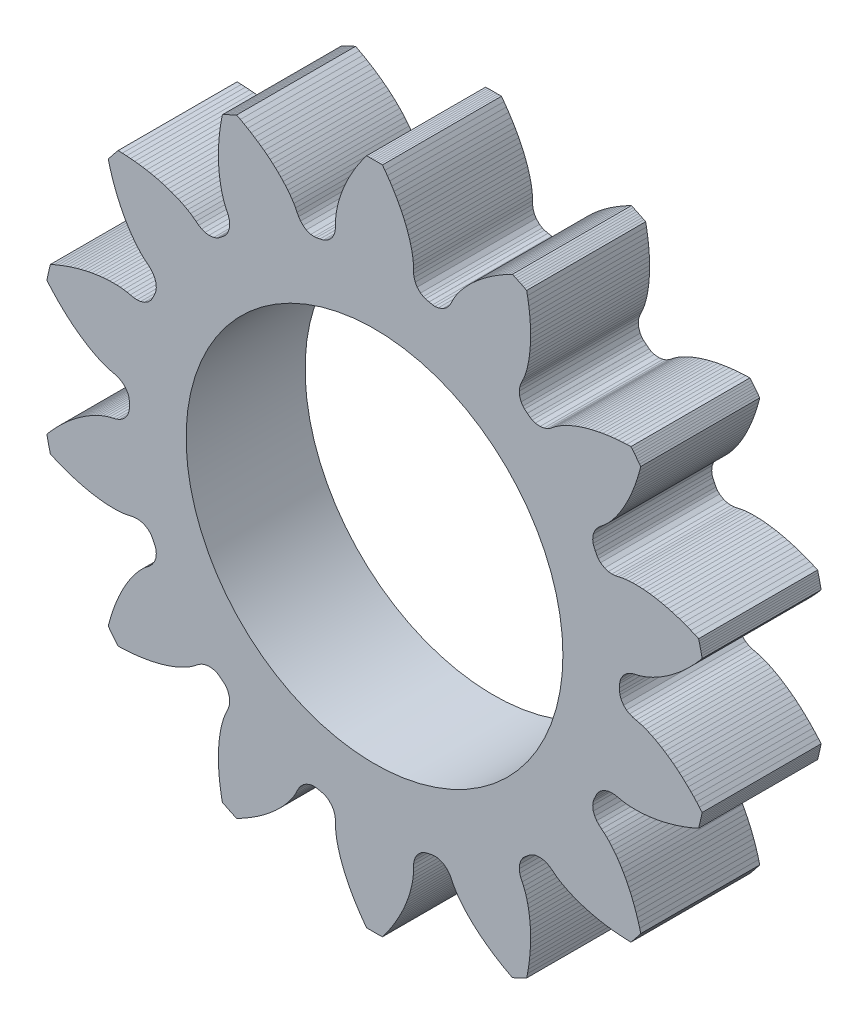
from build123d import *

# Parameters (mm, degrees)
SKETCH3_R      = 4.75
EXTRUDE2_DEPTH = 3


with BuildPart() as part:
    # Sketch3 → Extrude2 (new body)
    with BuildSketch(Plane.XY):
        Polygon((-1.373804192, 6.025054497), (-1.286136761, 6.046506249), (-1.231421429, 6.067958001), (-1.160814916, 6.110861505), (-1.076254106, 6.196668512), (-1.026667784, 6.282475519), (-0.997973478, 6.368282526), (-0.984540616, 6.454089534), (-0.982367604, 6.539896541), (-0.982078667, 6.625703548), (-0.975772464, 6.711510555), (-0.964874551, 6.797317563), (-0.950090272, 6.88312457), (-0.931820743, 6.968931577), (-0.910335182, 7.054738585), (-0.885840729, 7.140545592), (-0.8584406, 7.226352599), (-0.828288559, 7.312159606), (-0.795434627, 7.397966614), (-0.759924885, 7.483773621), (-0.721801696, 7.569580628), (-0.681103905, 7.655387635), (-0.637867032, 7.741194643), (-0.592118153, 7.82700165), (-0.543736138, 7.912808657), (-0.492864536, 7.998615664), (-0.439356223, 8.084422672), (-0.383311488, 8.170229679), (-0.324544258, 8.256036686), (-0.263173217, 8.341843694), (-0.199012902, 8.427650701), (-0.149265744, 8.428678556), (-0.099513385, 8.429412765), (-0.049757559, 8.4298533), (0, 8.430000147), (0.049757559, 8.4298533), (0.099513385, 8.429412765), (0.149265744, 8.428678556), (0.199012902, 8.427650701), (0.263173217, 8.341843694), (0.324544258, 8.256036686), (0.383311488, 8.170229679), (0.439356223, 8.084422672), (0.492864536, 7.998615664), (0.543736138, 7.912808657), (0.592118153, 7.82700165), (0.637867032, 7.741194643), (0.681103905, 7.655387635), (0.721801696, 7.569580628), (0.759924885, 7.483773621), (0.795434627, 7.397966614), (0.828288559, 7.312159606), (0.8584406, 7.226352599), (0.885840729, 7.140545592), (0.910335182, 7.054738585), (0.931820743, 6.968931577), (0.950090272, 6.88312457), (0.964874551, 6.797317563), (0.975772464, 6.711510555), (0.982078667, 6.625703548), (0.982367604, 6.539896541), (0.984540616, 6.454089534), (0.997973478, 6.368282526), (1.026667784, 6.282475519), (1.076254106, 6.196668512), (1.160814916, 6.110861505), (1.231421429, 6.067958001), (1.286136761, 6.046506249), (1.373804192, 6.025054497), (1.376418366, 6.024457829), (1.464711558, 6.005747717), (1.523315935, 6.001334985), (1.605545338, 6.009354688), (1.718962261, 6.04997457), (1.800868258, 6.105769313), (1.8639512, 6.170628762), (1.913284056, 6.242109904), (1.952472137, 6.318476512), (1.989962725, 6.395660589), (2.032874683, 6.470233872), (2.079923628, 6.542814887), (2.130474069, 6.613709671), (2.18416461, 6.683092262), (2.240752697, 6.751079468), (2.300051702, 6.817761166), (2.36196863, 6.883182138), (2.426364946, 6.9474091), (2.493195581, 7.010463755), (2.562419018, 7.072366098), (2.63399709, 7.133134508), (2.707894798, 7.19278584), (2.784080139, 7.251335506), (2.86252872, 7.308795254), (2.943349675, 7.365112526), (3.026413669, 7.420349608), (3.111853259, 7.474442663), (3.199578085, 7.527435206), (3.289755795, 7.579246503), (3.382279458, 7.629928048), (3.477316169, 7.679399373), (3.52258278, 7.658740956), (3.567726667, 7.637815715), (3.612746258, 7.61662438), (3.657639984, 7.595167688), (3.702406282, 7.573446388), (3.747043591, 7.551461236), (3.791550356, 7.529212998), (3.835925027, 7.506702449), (3.856501208, 7.40155489), (3.87456434, 7.29761755), (3.89028152, 7.194809963), (3.903545816, 7.093183622), (3.914524876, 6.992657792), (3.923128339, 6.893275989), (3.929488764, 6.794974377), (3.933476814, 6.697815241), (3.935201626, 6.601746022), (3.934638803, 6.50677847), (3.931756345, 6.412927996), (3.926519252, 6.320211454), (3.918889356, 6.228647225), (3.908825142, 6.138255303), (3.896281539, 6.04905739), (3.881120014, 5.961120203), (3.863247571, 5.874488525), (3.842477582, 5.789252232), (3.818567492, 5.705528131), (3.791155907, 5.623490262), (3.759607334, 5.543444661), (3.722637392, 5.466009854), (3.687364943, 5.387757577), (3.662237269, 5.304619834), (3.650859681, 5.214860399), (3.658305147, 5.116036258), (3.69726154, 5.002037255), (3.742260677, 4.932747516), (3.782249922, 4.889680063), (3.851927982, 4.83231523), (3.854024386, 4.830643403), (3.92545579, 4.775477194), (3.976341896, 4.746073973), (4.053907647, 4.717621476), (4.17371707, 4.705008966), (4.271720255, 4.719740613), (4.356697482, 4.750806294), (4.432159355, 4.793803854), (4.500600825, 4.845604718), (4.567867594, 4.898878612), (4.638886067, 4.947448018), (4.712767424, 4.992427481), (4.789071891, 5.03436846), (4.867549376, 5.073584562), (4.948032024, 5.110286267), (5.030390685, 5.144635527), (5.114561006, 5.176713037), (5.200447115, 5.206639016), (5.288017827, 5.234452572), (5.377244408, 5.260189732), (5.468100448, 5.283883616), (5.560561725, 5.305564596), (5.654606094, 5.325260441), (5.750216673, 5.342992321), (5.847468986, 5.358665532), (5.946273531, 5.372392307), (6.046722038, 5.384057617), (6.148751978, 5.393739873), (6.252479367, 5.401293596), (6.357830205, 5.406811578), (6.464920126, 5.410148818), (6.496740582, 5.371895781), (6.528334697, 5.333455592), (6.559701372, 5.29482959), (6.590839512, 5.256019121), (6.621748033, 5.217025537), (6.652425859, 5.177850197), (6.68287192, 5.138494465), (6.713085156, 5.098959713), (6.686001838, 4.995297366), (6.657179437, 4.893815759), (6.626733586, 4.794369895), (6.594590287, 4.697052563), (6.560865555, 4.601718285), (6.52549686, 4.508445471), (6.488575933, 4.417119094), (6.450013273, 4.327851387), (6.409884403, 4.240547644), (6.36817244, 4.155229036), (6.324855241, 4.071923332), (6.279908583, 3.990660904), (6.233306055, 3.911474872), (6.185018925, 3.834401263), (6.135016006, 3.759479186), (6.083201428, 3.686828857), (6.029510837, 3.616530975), (5.973815082, 3.548747489), (5.915946309, 3.48368888), (5.855654427, 3.421668754), (5.792499661, 3.363238572), (5.72559319, 3.309512878), (5.659861421, 3.254314155), (5.601150054, 3.190312127), (5.551954042, 3.114378221), (5.515783988, 3.022110279), (5.501420172, 2.902498182), (5.511899302, 2.82054589), (5.529242099, 2.764392773), (5.567130193, 2.682476666), (5.56829361, 2.680060807), (5.60871536, 2.599364845), (5.641804578, 2.550794805), (5.699343829, 2.491505472), (5.801816026, 2.428158633), (5.896505667, 2.3989094), (5.986546397, 2.390028375), (6.073191137, 2.396026158), (6.157330324, 2.413001483), (6.241050265, 2.431813646), (6.326109173, 2.444759408), (6.412189834, 2.453228584), (6.499135292, 2.457908833), (6.586856291, 2.459191215), (6.675292924, 2.457338197), (6.764399099, 2.452551726), (6.854151848, 2.444932432), (6.944516955, 2.43463022), (7.035483289, 2.421693861), (7.127040596, 2.406168277), (7.21917945, 2.388094771), (7.311891207, 2.367511214), (7.405167963, 2.344452235), (7.499003693, 2.318944232), (7.593425351, 2.29086911), (7.688400993, 2.260366821), (7.78396336, 2.227293928), (7.880090133, 2.191748208), (7.976822718, 2.15354825), (8.074134706, 2.112809764), (8.172067366, 2.069351938), (8.184139235, 2.021080764), (8.195925976, 1.972739178), (8.207427179, 1.924328863), (8.218642443, 1.875851506), (8.229571376, 1.827308796), (8.240213599, 1.778702425), (8.25056874, 1.730034085), (8.260636439, 1.681305472), (8.191257806, 1.599659935), (8.121258501, 1.520733738), (8.050679793, 1.44434607), (7.979495274, 1.370612639), (7.907746347, 1.299352035), (7.835410697, 1.230662035), (7.762521062, 1.164399202), (7.689045498, 1.100703488), (7.615010961, 1.039456799), (7.540411425, 0.980685531), (7.465238987, 0.924424314), (7.389485001, 0.87071102), (7.313140042, 0.819586949), (7.236193856, 0.771097027), (7.158635312, 0.725290022), (7.080430194, 0.68231584), (7.001555535, 0.642275111), (6.921965241, 0.605369783), (6.841599406, 0.571862321), (6.760368773, 0.542143786), (6.678116389, 0.516901837), (6.594525037, 0.497526289), (6.511352931, 0.476313904), (6.430686378, 0.444123976), (6.353415815, 0.39705524), (6.280794164, 0.329618296), (6.215955068, 0.228083746), (6.189838672, 0.149700558), (6.181100067, 0.091583591), (6.179693994, 0.001340701), (6.179693994, -0.001340701), (6.181100067, -0.091583591), (6.189838672, -0.149700558), (6.215955068, -0.228083746), (6.280794164, -0.329618296), (6.353415815, -0.39705524), (6.430686378, -0.444123976), (6.511352931, -0.476313904), (6.594525037, -0.497526289), (6.678116389, -0.516901837), (6.760368773, -0.542143786), (6.841599406, -0.571862321), (6.921965241, -0.605369783), (7.001555535, -0.642275111), (7.080430194, -0.68231584), (7.158635312, -0.725290022), (7.236193856, -0.771097027), (7.313140042, -0.819586949), (7.389485001, -0.87071102), (7.465238987, -0.924424314), (7.540411425, -0.980685531), (7.615010961, -1.039456799), (7.689045498, -1.100703488), (7.762521062, -1.164399202), (7.835410697, -1.230662035), (7.907746347, -1.299352035), (7.979495274, -1.370612639), (8.050679793, -1.44434607), (8.121258501, -1.520733738), (8.191257806, -1.599659935), (8.260636439, -1.681305472), (8.25056874, -1.730034085), (8.240213599, -1.778702425), (8.229571376, -1.827308796), (8.218642443, -1.875851506), (8.207427179, -1.924328863), (8.195925976, -1.972739178), (8.184139235, -2.021080764), (8.172067366, -2.069351938), (8.074134706, -2.112809764), (7.976822718, -2.15354825), (7.880090133, -2.191748208), (7.78396336, -2.227293928), (7.688400993, -2.260366821), (7.593425351, -2.29086911), (7.499003693, -2.318944232), (7.405167963, -2.344452235), (7.311891207, -2.367511214), (7.21917945, -2.388094771), (7.127040596, -2.406168277), (7.035483289, -2.421693861), (6.944516955, -2.43463022), (6.854151848, -2.444932432), (6.764399099, -2.452551726), (6.675292924, -2.457338197), (6.586856291, -2.459191215), (6.499135292, -2.457908833), (6.412189834, -2.453228584), (6.326109173, -2.444759408), (6.241050265, -2.431813646), (6.157330324, -2.413001483), (6.073191137, -2.396026158), (5.986546397, -2.390028375), (5.896505667, -2.3989094), (5.801816026, -2.428158633), (5.699343829, -2.491505472), (5.641804578, -2.550794805), (5.60871536, -2.599364845), (5.56829361, -2.680060807), (5.567130193, -2.682476666), (5.529242099, -2.764392773), (5.511899302, -2.82054589), (5.501420172, -2.902498182), (5.515783988, -3.022110279), (5.551954042, -3.114378221), (5.601150054, -3.190312127), (5.659861421, -3.254314155), (5.72559319, -3.309512878), (5.792499661, -3.363238572), (5.855654427, -3.421668754), (5.915946309, -3.48368888), (5.973815082, -3.548747489), (6.029510837, -3.616530975), (6.083201428, -3.686828857), (6.135016006, -3.759479186), (6.185018925, -3.834401263), (6.233306055, -3.911474872), (6.279908583, -3.990660904), (6.324855241, -4.071923332), (6.36817244, -4.155229036), (6.409884403, -4.240547644), (6.450013273, -4.327851387), (6.488575933, -4.417119094), (6.52549686, -4.508445471), (6.560865555, -4.601718285), (6.594590287, -4.697052563), (6.626733586, -4.794369895), (6.657179437, -4.893815759), (6.686001838, -4.995297366), (6.713085156, -5.098959713), (6.68287192, -5.138494465), (6.652425859, -5.177850197), (6.621748033, -5.217025537), (6.590839512, -5.256019121), (6.559701372, -5.29482959), (6.528334697, -5.333455592), (6.496740582, -5.371895781), (6.464920126, -5.410148818), (6.357830205, -5.406811578), (6.252479367, -5.401293596), (6.148751978, -5.393739873), (6.046722038, -5.384057617), (5.946273531, -5.372392307), (5.847468986, -5.358665532), (5.750216673, -5.342992321), (5.654606094, -5.325260441), (5.560561725, -5.305564596), (5.468100448, -5.283883616), (5.377244408, -5.260189732), (5.288017827, -5.234452572), (5.200447115, -5.206639016), (5.114561006, -5.176713037), (5.030390685, -5.144635527), (4.948032024, -5.110286267), (4.867549376, -5.073584562), (4.789071891, -5.03436846), (4.712767424, -4.992427481), (4.638886067, -4.947448018), (4.567867594, -4.898878612), (4.500600825, -4.845604718), (4.432159355, -4.793803854), (4.356697482, -4.750806294), (4.271720255, -4.719740613), (4.17371707, -4.705008966), (4.053907647, -4.717621476), (3.976341896, -4.746073973), (3.92545579, -4.775477194), (3.854024386, -4.830643403), (3.851927982, -4.83231523), (3.782249922, -4.889680063), (3.742260677, -4.932747516), (3.69726154, -5.002037255), (3.658305147, -5.116036258), (3.650859681, -5.214860399), (3.662237269, -5.304619834), (3.687364943, -5.387757577), (3.722637392, -5.466009854), (3.759607334, -5.543444661), (3.791155907, -5.623490262), (3.818567492, -5.705528131), (3.842477582, -5.789252232), (3.863247571, -5.874488525), (3.881120014, -5.961120203), (3.896281539, -6.04905739), (3.908825142, -6.138255303), (3.918889356, -6.228647225), (3.926519252, -6.320211454), (3.931756345, -6.412927996), (3.934638803, -6.50677847), (3.935201626, -6.601746022), (3.933476814, -6.697815241), (3.929488764, -6.794974377), (3.923128339, -6.893275989), (3.914524876, -6.992657792), (3.903545816, -7.093183622), (3.89028152, -7.194809963), (3.87456434, -7.29761755), (3.856501208, -7.40155489), (3.835925027, -7.506702449), (3.791550356, -7.529212998), (3.747043591, -7.551461236), (3.702406282, -7.573446388), (3.657639984, -7.595167688), (3.612746258, -7.61662438), (3.567726667, -7.637815715), (3.52258278, -7.658740956), (3.477316169, -7.679399373), (3.382279458, -7.629928048), (3.289755795, -7.579246503), (3.199578085, -7.527435206), (3.111853259, -7.474442663), (3.026413669, -7.420349608), (2.943349675, -7.365112526), (2.86252872, -7.308795254), (2.784080139, -7.251335506), (2.707894798, -7.19278584), (2.63399709, -7.133134508), (2.562419018, -7.072366098), (2.493195581, -7.010463755), (2.426364946, -6.9474091), (2.36196863, -6.883182138), (2.300051702, -6.817761166), (2.240752697, -6.751079468), (2.18416461, -6.683092262), (2.130474069, -6.613709671), (2.079923628, -6.542814887), (2.032874683, -6.470233872), (1.989962725, -6.395660589), (1.952472137, -6.318476512), (1.913284056, -6.242109904), (1.8639512, -6.170628762), (1.800868258, -6.105769313), (1.718962261, -6.04997457), (1.605545338, -6.009354688), (1.523315935, -6.001334985), (1.464711558, -6.005747717), (1.376418366, -6.024457829), (1.373804192, -6.025054497), (1.286136761, -6.046506249), (1.231421429, -6.067958001), (1.160814916, -6.110861505), (1.076254106, -6.196668512), (1.026667784, -6.282475519), (0.997973478, -6.368282526), (0.984540616, -6.454089534), (0.982367604, -6.539896541), (0.982078667, -6.625703548), (0.975772464, -6.711510555), (0.964874551, -6.797317563), (0.950090272, -6.88312457), (0.931820743, -6.968931577), (0.910335182, -7.054738585), (0.885840729, -7.140545592), (0.8584406, -7.226352599), (0.828288559, -7.312159606), (0.795434627, -7.397966614), (0.759924885, -7.483773621), (0.721801696, -7.569580628), (0.681103905, -7.655387635), (0.637867032, -7.741194643), (0.592118153, -7.82700165), (0.543736138, -7.912808657), (0.492864536, -7.998615664), (0.439356223, -8.084422672), (0.383311488, -8.170229679), (0.324544258, -8.256036686), (0.263173217, -8.341843694), (0.199012902, -8.427650701), (0.149265744, -8.428678556), (0.099513385, -8.429412765), (0.049757559, -8.4298533), (0, -8.430000147), (-0.049757559, -8.4298533), (-0.099513385, -8.429412765), (-0.149265744, -8.428678556), (-0.199012902, -8.427650701), (-0.263173217, -8.341843694), (-0.324544258, -8.256036686), (-0.383311488, -8.170229679), (-0.439356223, -8.084422672), (-0.492864536, -7.998615664), (-0.543736138, -7.912808657), (-0.592118153, -7.82700165), (-0.637867032, -7.741194643), (-0.681103905, -7.655387635), (-0.721801696, -7.569580628), (-0.759924885, -7.483773621), (-0.795434627, -7.397966614), (-0.828288559, -7.312159606), (-0.8584406, -7.226352599), (-0.885840729, -7.140545592), (-0.910335182, -7.054738585), (-0.931820743, -6.968931577), (-0.950090272, -6.88312457), (-0.964874551, -6.797317563), (-0.975772464, -6.711510555), (-0.982078667, -6.625703548), (-0.982367604, -6.539896541), (-0.984540616, -6.454089534), (-0.997973478, -6.368282526), (-1.026667784, -6.282475519), (-1.076254106, -6.196668512), (-1.160814916, -6.110861505), (-1.231421429, -6.067958001), (-1.286136761, -6.046506249), (-1.373804192, -6.025054497), (-1.376418366, -6.024457829), (-1.464711558, -6.005747717), (-1.523315935, -6.001334985), (-1.605545338, -6.009354688), (-1.718962261, -6.04997457), (-1.800868258, -6.105769313), (-1.8639512, -6.170628762), (-1.913284056, -6.242109904), (-1.952472137, -6.318476512), (-1.989962725, -6.395660589), (-2.032874683, -6.470233872), (-2.079923628, -6.542814887), (-2.130474069, -6.613709671), (-2.18416461, -6.683092262), (-2.240752697, -6.751079468), (-2.300051702, -6.817761166), (-2.36196863, -6.883182138), (-2.426364946, -6.9474091), (-2.493195581, -7.010463755), (-2.562419018, -7.072366098), (-2.63399709, -7.133134508), (-2.707894798, -7.19278584), (-2.784080139, -7.251335506), (-2.86252872, -7.308795254), (-2.943349675, -7.365112526), (-3.026413669, -7.420349608), (-3.111853259, -7.474442663), (-3.199578085, -7.527435206), (-3.289755795, -7.579246503), (-3.382279458, -7.629928048), (-3.477316169, -7.679399373), (-3.52258278, -7.658740956), (-3.567726667, -7.637815715), (-3.612746258, -7.61662438), (-3.657639984, -7.595167688), (-3.702406282, -7.573446388), (-3.747043591, -7.551461236), (-3.791550356, -7.529212998), (-3.835925027, -7.506702449), (-3.856501208, -7.40155489), (-3.87456434, -7.29761755), (-3.89028152, -7.194809963), (-3.903545816, -7.093183622), (-3.914524876, -6.992657792), (-3.923128339, -6.893275989), (-3.929488764, -6.794974377), (-3.933476814, -6.697815241), (-3.935201626, -6.601746022), (-3.934638803, -6.50677847), (-3.931756345, -6.412927996), (-3.926519252, -6.320211454), (-3.918889356, -6.228647225), (-3.908825142, -6.138255303), (-3.896281539, -6.04905739), (-3.881120014, -5.961120203), (-3.863247571, -5.874488525), (-3.842477582, -5.789252232), (-3.818567492, -5.705528131), (-3.791155907, -5.623490262), (-3.759607334, -5.543444661), (-3.722637392, -5.466009854), (-3.687364943, -5.387757577), (-3.662237269, -5.304619834), (-3.650859681, -5.214860399), (-3.658305147, -5.116036258), (-3.69726154, -5.002037255), (-3.742260677, -4.932747516), (-3.782249922, -4.889680063), (-3.851927982, -4.83231523), (-3.854024386, -4.830643403), (-3.92545579, -4.775477194), (-3.976341896, -4.746073973), (-4.053907647, -4.717621476), (-4.17371707, -4.705008966), (-4.271720255, -4.719740613), (-4.356697482, -4.750806294), (-4.432159355, -4.793803854), (-4.500600825, -4.845604718), (-4.567867594, -4.898878612), (-4.638886067, -4.947448018), (-4.712767424, -4.992427481), (-4.789071891, -5.03436846), (-4.867549376, -5.073584562), (-4.948032024, -5.110286267), (-5.030390685, -5.144635527), (-5.114561006, -5.176713037), (-5.200447115, -5.206639016), (-5.288017827, -5.234452572), (-5.377244408, -5.260189732), (-5.468100448, -5.283883616), (-5.560561725, -5.305564596), (-5.654606094, -5.325260441), (-5.750216673, -5.342992321), (-5.847468986, -5.358665532), (-5.946273531, -5.372392307), (-6.046722038, -5.384057617), (-6.148751978, -5.393739873), (-6.252479367, -5.401293596), (-6.357830205, -5.406811578), (-6.464920126, -5.410148818), (-6.496740582, -5.371895781), (-6.528334697, -5.333455592), (-6.559701372, -5.29482959), (-6.590839512, -5.256019121), (-6.621748033, -5.217025537), (-6.652425859, -5.177850197), (-6.68287192, -5.138494465), (-6.713085156, -5.098959713), (-6.686001838, -4.995297366), (-6.657179437, -4.893815759), (-6.626733586, -4.794369895), (-6.594590287, -4.697052563), (-6.560865555, -4.601718285), (-6.52549686, -4.508445471), (-6.488575933, -4.417119094), (-6.450013273, -4.327851387), (-6.409884403, -4.240547644), (-6.36817244, -4.155229036), (-6.324855241, -4.071923332), (-6.279908583, -3.990660904), (-6.233306055, -3.911474872), (-6.185018925, -3.834401263), (-6.135016006, -3.759479186), (-6.083201428, -3.686828857), (-6.029510837, -3.616530975), (-5.973815082, -3.548747489), (-5.915946309, -3.48368888), (-5.855654427, -3.421668754), (-5.792499661, -3.363238572), (-5.72559319, -3.309512878), (-5.659861421, -3.254314155), (-5.601150054, -3.190312127), (-5.551954042, -3.114378221), (-5.515783988, -3.022110279), (-5.501420172, -2.902498182), (-5.511899302, -2.82054589), (-5.529242099, -2.764392773), (-5.567130193, -2.682476666), (-5.56829361, -2.680060807), (-5.60871536, -2.599364845), (-5.641804578, -2.550794805), (-5.699343829, -2.491505472), (-5.801816026, -2.428158633), (-5.896505667, -2.3989094), (-5.986546397, -2.390028375), (-6.073191137, -2.396026158), (-6.157330324, -2.413001483), (-6.241050265, -2.431813646), (-6.326109173, -2.444759408), (-6.412189834, -2.453228584), (-6.499135292, -2.457908833), (-6.586856291, -2.459191215), (-6.675292924, -2.457338197), (-6.764399099, -2.452551726), (-6.854151848, -2.444932432), (-6.944516955, -2.43463022), (-7.035483289, -2.421693861), (-7.127040596, -2.406168277), (-7.21917945, -2.388094771), (-7.311891207, -2.367511214), (-7.405167963, -2.344452235), (-7.499003693, -2.318944232), (-7.593425351, -2.29086911), (-7.688400993, -2.260366821), (-7.78396336, -2.227293928), (-7.880090133, -2.191748208), (-7.976822718, -2.15354825), (-8.074134706, -2.112809764), (-8.172067366, -2.069351938), (-8.184139235, -2.021080764), (-8.195925976, -1.972739178), (-8.207427179, -1.924328863), (-8.218642443, -1.875851506), (-8.229571376, -1.827308796), (-8.240213599, -1.778702425), (-8.25056874, -1.730034085), (-8.260636439, -1.681305472), (-8.191257806, -1.599659935), (-8.121258501, -1.520733738), (-8.050679793, -1.44434607), (-7.979495274, -1.370612639), (-7.907746347, -1.299352035), (-7.835410697, -1.230662035), (-7.762521062, -1.164399202), (-7.689045498, -1.100703488), (-7.615010961, -1.039456799), (-7.540411425, -0.980685531), (-7.465238987, -0.924424314), (-7.389485001, -0.87071102), (-7.313140042, -0.819586949), (-7.236193856, -0.771097027), (-7.158635312, -0.725290022), (-7.080430194, -0.68231584), (-7.001555535, -0.642275111), (-6.921965241, -0.605369783), (-6.841599406, -0.571862321), (-6.760368773, -0.542143786), (-6.678116389, -0.516901837), (-6.594525037, -0.497526289), (-6.511352931, -0.476313904), (-6.430686378, -0.444123976), (-6.353415815, -0.39705524), (-6.280794164, -0.329618296), (-6.215955068, -0.228083746), (-6.189838672, -0.149700558), (-6.181100067, -0.091583591), (-6.179693994, -0.001340701), (-6.179693994, 0.001340701), (-6.181100067, 0.091583591), (-6.189838672, 0.149700558), (-6.215955068, 0.228083746), (-6.280794164, 0.329618296), (-6.353415815, 0.39705524), (-6.430686378, 0.444123976), (-6.511352931, 0.476313904), (-6.594525037, 0.497526289), (-6.678116389, 0.516901837), (-6.760368773, 0.542143786), (-6.841599406, 0.571862321), (-6.921965241, 0.605369783), (-7.001555535, 0.642275111), (-7.080430194, 0.68231584), (-7.158635312, 0.725290022), (-7.236193856, 0.771097027), (-7.313140042, 0.819586949), (-7.389485001, 0.87071102), (-7.465238987, 0.924424314), (-7.540411425, 0.980685531), (-7.615010961, 1.039456799), (-7.689045498, 1.100703488), (-7.762521062, 1.164399202), (-7.835410697, 1.230662035), (-7.907746347, 1.299352035), (-7.979495274, 1.370612639), (-8.050679793, 1.44434607), (-8.121258501, 1.520733738), (-8.191257806, 1.599659935), (-8.260636439, 1.681305472), (-8.25056874, 1.730034085), (-8.240213599, 1.778702425), (-8.229571376, 1.827308796), (-8.218642443, 1.875851506), (-8.207427179, 1.924328863), (-8.195925976, 1.972739178), (-8.184139235, 2.021080764), (-8.172067366, 2.069351938), (-8.074134706, 2.112809764), (-7.976822718, 2.15354825), (-7.880090133, 2.191748208), (-7.78396336, 2.227293928), (-7.688400993, 2.260366821), (-7.593425351, 2.29086911), (-7.499003693, 2.318944232), (-7.405167963, 2.344452235), (-7.311891207, 2.367511214), (-7.21917945, 2.388094771), (-7.127040596, 2.406168277), (-7.035483289, 2.421693861), (-6.944516955, 2.43463022), (-6.854151848, 2.444932432), (-6.764399099, 2.452551726), (-6.675292924, 2.457338197), (-6.586856291, 2.459191215), (-6.499135292, 2.457908833), (-6.412189834, 2.453228584), (-6.326109173, 2.444759408), (-6.241050265, 2.431813646), (-6.157330324, 2.413001483), (-6.073191137, 2.396026158), (-5.986546397, 2.390028375), (-5.896505667, 2.3989094), (-5.801816026, 2.428158633), (-5.699343829, 2.491505472), (-5.641804578, 2.550794805), (-5.60871536, 2.599364845), (-5.56829361, 2.680060807), (-5.567130193, 2.682476666), (-5.529242099, 2.764392773), (-5.511899302, 2.82054589), (-5.501420172, 2.902498182), (-5.515783988, 3.022110279), (-5.551954042, 3.114378221), (-5.601150054, 3.190312127), (-5.659861421, 3.254314155), (-5.72559319, 3.309512878), (-5.792499661, 3.363238572), (-5.855654427, 3.421668754), (-5.915946309, 3.48368888), (-5.973815082, 3.548747489), (-6.029510837, 3.616530975), (-6.083201428, 3.686828857), (-6.135016006, 3.759479186), (-6.185018925, 3.834401263), (-6.233306055, 3.911474872), (-6.279908583, 3.990660904), (-6.324855241, 4.071923332), (-6.36817244, 4.155229036), (-6.409884403, 4.240547644), (-6.450013273, 4.327851387), (-6.488575933, 4.417119094), (-6.52549686, 4.508445471), (-6.560865555, 4.601718285), (-6.594590287, 4.697052563), (-6.626733586, 4.794369895), (-6.657179437, 4.893815759), (-6.686001838, 4.995297366), (-6.713085156, 5.098959713), (-6.68287192, 5.138494465), (-6.652425859, 5.177850197), (-6.621748033, 5.217025537), (-6.590839512, 5.256019121), (-6.559701372, 5.29482959), (-6.528334697, 5.333455592), (-6.496740582, 5.371895781), (-6.464920126, 5.410148818), (-6.357830205, 5.406811578), (-6.252479367, 5.401293596), (-6.148751978, 5.393739873), (-6.046722038, 5.384057617), (-5.946273531, 5.372392307), (-5.847468986, 5.358665532), (-5.750216673, 5.342992321), (-5.654606094, 5.325260441), (-5.560561725, 5.305564596), (-5.468100448, 5.283883616), (-5.377244408, 5.260189732), (-5.288017827, 5.234452572), (-5.200447115, 5.206639016), (-5.114561006, 5.176713037), (-5.030390685, 5.144635527), (-4.948032024, 5.110286267), (-4.867549376, 5.073584562), (-4.789071891, 5.03436846), (-4.712767424, 4.992427481), (-4.638886067, 4.947448018), (-4.567867594, 4.898878612), (-4.500600825, 4.845604718), (-4.432159355, 4.793803854), (-4.356697482, 4.750806294), (-4.271720255, 4.719740613), (-4.17371707, 4.705008966), (-4.053907647, 4.717621476), (-3.976341896, 4.746073973), (-3.92545579, 4.775477194), (-3.854024386, 4.830643403), (-3.851927982, 4.83231523), (-3.782249922, 4.889680063), (-3.742260677, 4.932747516), (-3.69726154, 5.002037255), (-3.658305147, 5.116036258), (-3.650859681, 5.214860399), (-3.662237269, 5.304619834), (-3.687364943, 5.387757577), (-3.722637392, 5.466009854), (-3.759607334, 5.543444661), (-3.791155907, 5.623490262), (-3.818567492, 5.705528131), (-3.842477582, 5.789252232), (-3.863247571, 5.874488525), (-3.881120014, 5.961120203), (-3.896281539, 6.04905739), (-3.908825142, 6.138255303), (-3.918889356, 6.228647225), (-3.926519252, 6.320211454), (-3.931756345, 6.412927996), (-3.934638803, 6.50677847), (-3.935201626, 6.601746022), (-3.933476814, 6.697815241), (-3.929488764, 6.794974377), (-3.923128339, 6.893275989), (-3.914524876, 6.992657792), (-3.903545816, 7.093183622), (-3.89028152, 7.194809963), (-3.87456434, 7.29761755), (-3.856501208, 7.40155489), (-3.835925027, 7.506702449), (-3.791550356, 7.529212998), (-3.747043591, 7.551461236), (-3.702406282, 7.573446388), (-3.657639984, 7.595167688), (-3.612746258, 7.61662438), (-3.567726667, 7.637815715), (-3.52258278, 7.658740956), (-3.477316169, 7.679399373), (-3.382279458, 7.629928048), (-3.289755795, 7.579246503), (-3.199578085, 7.527435206), (-3.111853259, 7.474442663), (-3.026413669, 7.420349608), (-2.943349675, 7.365112526), (-2.86252872, 7.308795254), (-2.784080139, 7.251335506), (-2.707894798, 7.19278584), (-2.63399709, 7.133134508), (-2.562419018, 7.072366098), (-2.493195581, 7.010463755), (-2.426364946, 6.9474091), (-2.36196863, 6.883182138), (-2.300051702, 6.817761166), (-2.240752697, 6.751079468), (-2.18416461, 6.683092262), (-2.130474069, 6.613709671), (-2.079923628, 6.542814887), (-2.032874683, 6.470233872), (-1.989962725, 6.395660589), (-1.952472137, 6.318476512), (-1.913284056, 6.242109904), (-1.8639512, 6.170628762), (-1.800868258, 6.105769313), (-1.718962261, 6.04997457), (-1.605545338, 6.009354688), (-1.523315935, 6.001334985), (-1.464711558, 6.005747717), (-1.376418366, 6.024457829), align=None)
        Circle(SKETCH3_R, mode=Mode.SUBTRACT)
    extrude(amount=EXTRUDE2_DEPTH)


solid = part.part
